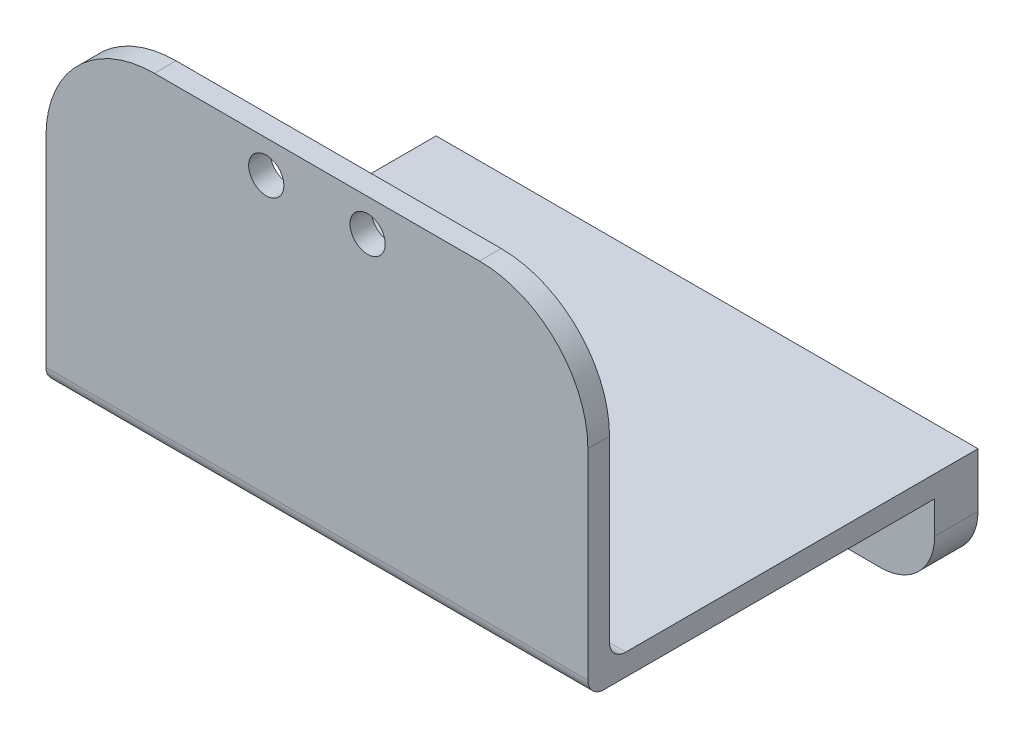
from build123d import *

# Parameters (mm, degrees)
SKETCH1_W                = 50
SKETCH1_H                = 8
SKETCH1_R                = 1.5
BOSS_EXTRUDE1_DEPTH      = 4
SKETCH2_W                = 50
SKETCH2_H                = 2
BOSS_EXTRUDE2_DEPTH      = 30
BOSS_EXTRUDE2_DEPTH_BACK = 4
SKETCH3_W                = 2
SKETCH3_H                = 30
BOSS_EXTRUDE3_DEPTH      = 50
FILLET1_R                = 10
FILLET2_R                = 5
FILLET3_R                = 1.5
SKETCH4_R                = 1.625
CUT_EXTRUDE1_DEPTH       = 13


with BuildPart() as part:
    # Sketch1 → Boss-Extrude1 (new body)
    with BuildSketch(Plane.XY):
        with Locations((-29.042911783, 15.053723554)):
            Rectangle(SKETCH1_W, SKETCH1_H)
        with Locations((-41.180553897, 15.053723554)):
            Circle(SKETCH1_R, mode=Mode.SUBTRACT)
        with Locations((-16.905269669, 15.053723554)):
            Circle(SKETCH1_R, mode=Mode.SUBTRACT)
    extrude(amount=BOSS_EXTRUDE1_DEPTH)

    # Sketch2 → Boss-Extrude2 (add, two sides)
    with BuildSketch(Plane.XY.offset(4)) as boss_extrude2_sk:
        with Locations((-29.042911783, 20.053723554)):
            Rectangle(SKETCH2_W, SKETCH2_H)
    extrude(amount=BOSS_EXTRUDE2_DEPTH)
    extrude(boss_extrude2_sk.sketch, amount=-BOSS_EXTRUDE2_DEPTH_BACK)

    # Sketch3 → Boss-Extrude3 (add)
    with BuildSketch(Plane.ZY.offset(54.042911783)):
        with Locations((35, 34.053723554)):
            Rectangle(SKETCH3_W, SKETCH3_H)
    extrude(amount=-BOSS_EXTRUDE3_DEPTH)

    # Fillet1
    fillet1_edges = [part.edges().sort_by_distance(p)[0] for p in [
        (-4.042911783, 49.053723554, 35),
        (-54.042911783, 49.053723554, 35),
    ]]
    fillet(fillet1_edges, radius=FILLET1_R)

    # Fillet2
    fillet2_edges = [part.edges().sort_by_distance(p)[0] for p in [
        (-54.042911783, 11.053723554, 2),
        (-4.042911783, 11.053723554, 2),
    ]]
    fillet(fillet2_edges, radius=FILLET2_R)

    # Fillet3
    fillet3_edges = [part.edges().sort_by_distance(p)[0] for p in [
        (-29.042911783, 21.053723554, 34),
        (-29.042911783, 19.053723554, 36),
    ]]
    fillet(fillet3_edges, radius=FILLET3_R)

    # Sketch4 → Cut-Extrude1 (cut)
    with BuildSketch(Plane.XY.offset(36)):
        with Locations((-24.367911783, 46.053723554)):
            Circle(SKETCH4_R)
        with Locations((-33.717911783, 46.053723554)):
            Circle(SKETCH4_R)
    extrude(amount=-CUT_EXTRUDE1_DEPTH, mode=Mode.SUBTRACT)


solid = part.part
